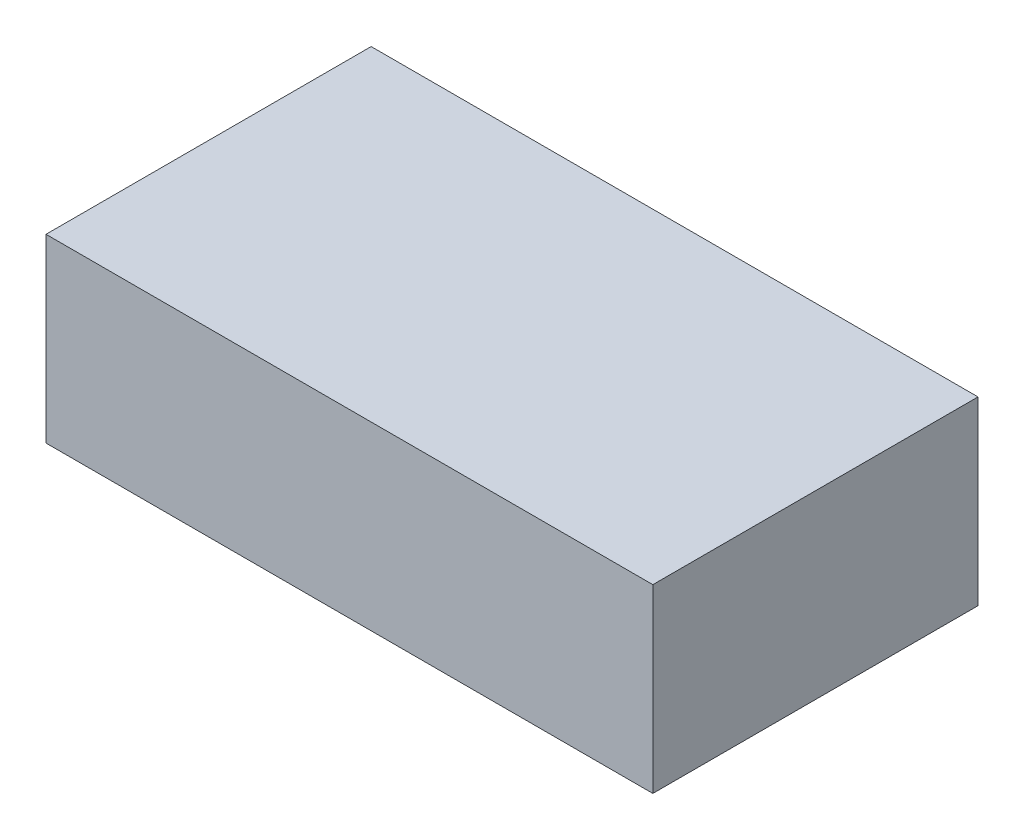
from build123d import *

# Parameters (mm, degrees)
SKETCH1_W           = 30.9
SKETCH1_H           = 14.7
BOSS_EXTRUDE1_DEPTH = 2
SKETCH2_W           = 30.9
SKETCH2_H           = 2
BOSS_EXTRUDE2_DEPTH = 10.4


with BuildPart() as part:
    # Sketch1 → Boss-Extrude1 (new body)
    with BuildSketch(Plane(origin=(0, 0, 0), x_dir=(1, 0, 0), z_dir=(0, 1, 0))):
        with Locations((15.45, 7.35)):
            Rectangle(SKETCH1_W, SKETCH1_H)
    extrude(amount=BOSS_EXTRUDE1_DEPTH)

    # Sketch2 → Boss-Extrude2 (add)
    with BuildSketch(Plane(origin=(0, 2, 0), x_dir=(1, 0, 0), z_dir=(0, 1, 0))):
        Polygon((0, 16.7), (-2, 16.7), (-2, -2), (0, -2), (0, 0), (0, 14.7), align=None)
        with Locations((15.45, 15.7)):
            Rectangle(SKETCH2_W, SKETCH2_H)
        with Locations((15.45, -1)):
            Rectangle(SKETCH2_W, SKETCH2_H)
        Polygon((32.9, 16.7), (32.9, -2), (30.9, -2), (30.9, 0), (30.9, 14.7), (30.9, 16.7), align=None)
    extrude(amount=-BOSS_EXTRUDE2_DEPTH)


solid = part.part
